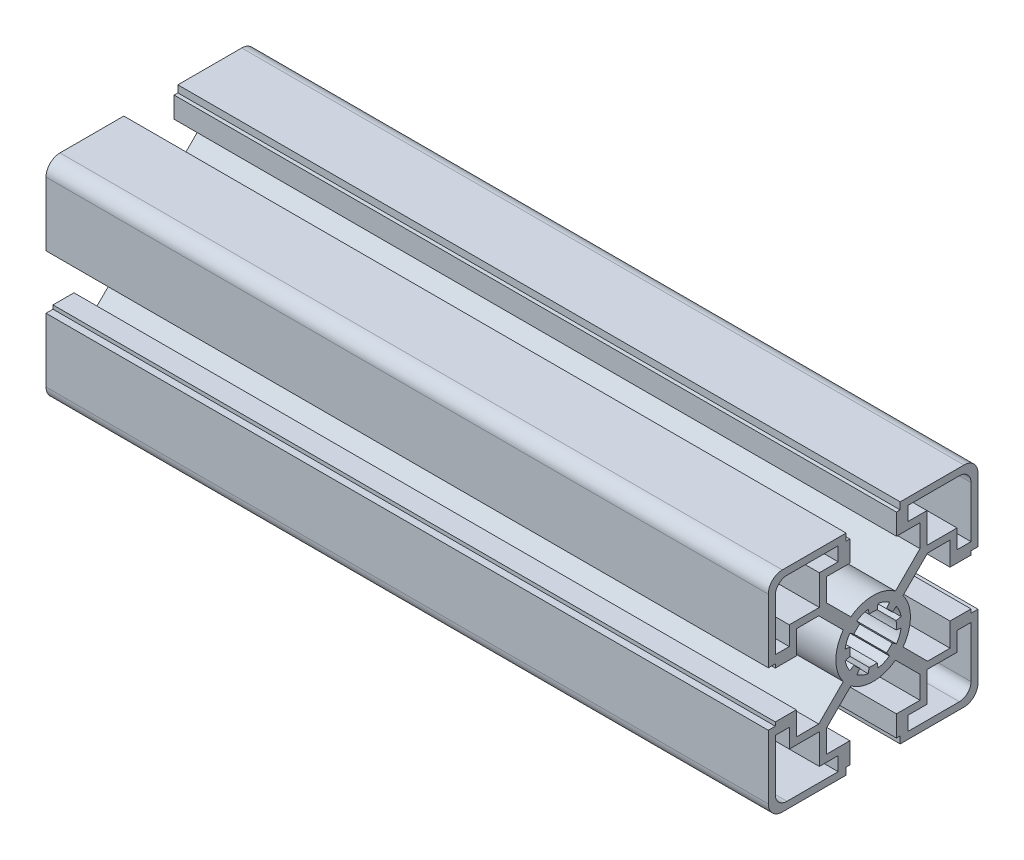
from build123d import *

# Parameters (mm, degrees)
BR_EXTRUDE_DEPTH      = 77.5
BR_EXTRUDE_DEPTH_BACK = 77.5


with BuildPart() as part:
    # Sketch2 → BR_Extrude (new body, two sides)
    with BuildSketch(Plane(origin=(0, 0, 0), x_dir=(0, 0, -1), z_dir=(1, 0, 0))) as br_extrude_sk:
        with BuildLine():
            Line((-10.05, 11.676345597), (-10.05, 16.5))
            Line((-10.05, 16.5), (-5, 16.5))
            Line((-5, 16.5), (-5, 21))
            Line((-5, 21), (-5.8, 21))
            Line((-5.8, 21), (-5.8, 22.5))
            Line((-5.8, 22.5), (-19.5, 22.5))
            ThreePointArc((-19.5, 22.5), (-21.621320344, 21.621320344), (-22.5, 19.5))
            Line((-22.5, 19.5), (-22.5, 5.8))
            Line((-22.5, 5.8), (-21, 5.8))
            Line((-21, 5.8), (-21, 5))
            Line((-21, 5), (-16.5, 5))
            Line((-16.5, 5), (-16.5, 10.05))
            Line((-16.5, 10.05), (-11.676345597, 10.05))
            Line((-11.676345597, 10.05), (-6.411275155, 4.784929559))
            ThreePointArc((-6.411275155, 4.784929559), (-8, 0), (-6.411275155, -4.784929559))
            Line((-6.411275155, -4.784929559), (-11.676345597, -10.05))
            Line((-11.676345597, -10.05), (-16.5, -10.05))
            Line((-16.5, -10.05), (-16.5, -5))
            Line((-16.5, -5), (-21, -5))
            Line((-21, -5), (-21, -5.8))
            Line((-21, -5.8), (-22.5, -5.8))
            Line((-22.5, -5.8), (-22.5, -19.5))
            ThreePointArc((-22.5, -19.5), (-21.621320344, -21.621320344), (-19.5, -22.5))
            Line((-19.5, -22.5), (-5.8, -22.5))
            Line((-5.8, -22.5), (-5.8, -21))
            Line((-5.8, -21), (-5, -21))
            Line((-5, -21), (-5, -16.5))
            Line((-5, -16.5), (-10.05, -16.5))
            Line((-10.05, -16.5), (-10.05, -11.676345597))
            Line((-10.05, -11.676345597), (-4.784929559, -6.411275155))
            ThreePointArc((-4.784929559, -6.411275155), (0, -8), (4.784929559, -6.411275155))
            Line((4.784929559, -6.411275155), (10.05, -11.676345597))
            Line((10.05, -11.676345597), (10.05, -16.5))
            Line((10.05, -16.5), (5, -16.5))
            Line((5, -16.5), (5, -21))
            Line((5, -21), (5.8, -21))
            Line((5.8, -21), (5.8, -22.5))
            Line((5.8, -22.5), (19.5, -22.5))
            ThreePointArc((19.5, -22.5), (21.621320344, -21.621320344), (22.5, -19.5))
            Line((22.5, -19.5), (22.5, -5.8))
            Line((22.5, -5.8), (21, -5.8))
            Line((21, -5.8), (21, -5))
            Line((21, -5), (16.5, -5))
            Line((16.5, -5), (16.5, -10.05))
            Line((16.5, -10.05), (11.676345597, -10.05))
            Line((11.676345597, -10.05), (6.411275155, -4.784929559))
            ThreePointArc((6.411275155, -4.784929559), (8, 0), (6.411275155, 4.784929559))
            Line((6.411275155, 4.784929559), (11.676345597, 10.05))
            Line((11.676345597, 10.05), (16.5, 10.05))
            Line((16.5, 10.05), (16.5, 5))
            Line((16.5, 5), (21, 5))
            Line((21, 5), (21, 5.8))
            Line((21, 5.8), (22.5, 5.8))
            Line((22.5, 5.8), (22.5, 19.5))
            ThreePointArc((22.5, 19.5), (21.621320344, 21.621320344), (19.5, 22.5))
            Line((19.5, 22.5), (5.8, 22.5))
            Line((5.8, 22.5), (5.8, 21))
            Line((5.8, 21), (5, 21))
            Line((5, 21), (5, 16.5))
            Line((5, 16.5), (10.05, 16.5))
            Line((10.05, 16.5), (10.05, 11.676345597))
            Line((10.05, 11.676345597), (4.784929559, 6.411275155))
            ThreePointArc((4.784929559, 6.411275155), (0, 8), (-4.784929559, 6.411275155))
            Line((-4.784929559, 6.411275155), (-10.05, 11.676345597))
        make_face()
        with BuildLine():
            Line((11.55, 11.55), (11.55, 18))
            Line((11.55, 18), (7.5, 18))
            Line((7.5, 18), (7.5, 21))
            Line((7.5, 21), (18.5, 21))
            ThreePointArc((18.5, 21), (20.267766953, 20.267766953), (21, 18.5))
            Line((21, 18.5), (21, 7.5))
            Line((21, 7.5), (18, 7.5))
            Line((18, 7.5), (18, 11.55))
            Line((18, 11.55), (11.55, 11.55))
        make_face(mode=Mode.SUBTRACT)
        with BuildLine():
            Line((11.55, -11.55), (18, -11.55))
            Line((18, -11.55), (18, -7.5))
            Line((18, -7.5), (21, -7.5))
            Line((21, -7.5), (21, -18.5))
            ThreePointArc((21, -18.5), (20.267766953, -20.267766953), (18.5, -21))
            Line((18.5, -21), (7.5, -21))
            Line((7.5, -21), (7.5, -18))
            Line((7.5, -18), (11.55, -18))
            Line((11.55, -18), (11.55, -11.55))
        make_face(mode=Mode.SUBTRACT)
        with BuildLine():
            Line((-11.55, 11.55), (-18, 11.55))
            Line((-18, 11.55), (-18, 7.5))
            Line((-18, 7.5), (-21, 7.5))
            Line((-21, 7.5), (-21, 18.5))
            ThreePointArc((-21, 18.5), (-20.267766953, 20.267766953), (-18.5, 21))
            Line((-18.5, 21), (-7.5, 21))
            Line((-7.5, 21), (-7.5, 18))
            Line((-7.5, 18), (-11.55, 18))
            Line((-11.55, 18), (-11.55, 11.55))
        make_face(mode=Mode.SUBTRACT)
        with BuildLine():
            Line((-11.55, -11.55), (-11.55, -18))
            Line((-11.55, -18), (-7.5, -18))
            Line((-7.5, -18), (-7.5, -21))
            Line((-7.5, -21), (-18.5, -21))
            ThreePointArc((-18.5, -21), (-20.267766953, -20.267766953), (-21, -18.5))
            Line((-21, -18.5), (-21, -7.5))
            Line((-21, -7.5), (-18, -7.5))
            Line((-18, -7.5), (-18, -11.55))
            Line((-18, -11.55), (-11.55, -11.55))
        make_face(mode=Mode.SUBTRACT)
        with BuildLine():
            Line((-6.007327293, -1.059253884), (-4.924038765, -0.868240888))
            ThreePointArc((-4.924038765, -0.868240888), (-5, 0), (-4.924038765, 0.868240888))
            Line((-4.924038765, 0.868240888), (-6.007327293, 1.059253884))
            ThreePointArc((-6.007327293, 1.059253884), (-5.635665148, 2.334368937), (-4.99682747, 3.498816262))
            Line((-4.99682747, 3.498816262), (-4.095760221, 2.867882182))
            ThreePointArc((-4.095760221, 2.867882182), (-3.535533906, 3.535533906), (-2.867882182, 4.095760221))
            Line((-2.867882182, 4.095760221), (-3.498816262, 4.99682747))
            ThreePointArc((-3.498816262, 4.99682747), (-2.334368937, 5.635665148), (-1.059253884, 6.007327293))
            Line((-1.059253884, 6.007327293), (-0.868240888, 4.924038765))
            ThreePointArc((-0.868240888, 4.924038765), (0, 5), (0.868240888, 4.924038765))
            Line((0.868240888, 4.924038765), (1.059253884, 6.007327293))
            ThreePointArc((1.059253884, 6.007327293), (2.334368937, 5.635665148), (3.498816262, 4.99682747))
            Line((3.498816262, 4.99682747), (2.867882182, 4.095760221))
            ThreePointArc((2.867882182, 4.095760221), (3.535533906, 3.535533906), (4.095760221, 2.867882182))
            Line((4.095760221, 2.867882182), (4.99682747, 3.498816262))
            ThreePointArc((4.99682747, 3.498816262), (5.635665148, 2.334368937), (6.007327293, 1.059253884))
            Line((6.007327293, 1.059253884), (4.924038765, 0.868240888))
            ThreePointArc((4.924038765, 0.868240888), (5, 0), (4.924038765, -0.868240888))
            Line((4.924038765, -0.868240888), (6.007327293, -1.059253884))
            ThreePointArc((6.007327293, -1.059253884), (5.635665148, -2.334368937), (4.99682747, -3.498816262))
            Line((4.99682747, -3.498816262), (4.095760221, -2.867882182))
            ThreePointArc((4.095760221, -2.867882182), (3.535533906, -3.535533906), (2.867882182, -4.095760221))
            Line((2.867882182, -4.095760221), (3.498816262, -4.99682747))
            ThreePointArc((3.498816262, -4.99682747), (2.334368937, -5.635665148), (1.059253884, -6.007327293))
            Line((1.059253884, -6.007327293), (0.868240888, -4.924038765))
            ThreePointArc((0.868240888, -4.924038765), (0, -5), (-0.868240888, -4.924038765))
            Line((-0.868240888, -4.924038765), (-1.059253884, -6.007327293))
            ThreePointArc((-1.059253884, -6.007327293), (-2.334368937, -5.635665148), (-3.498816262, -4.99682747))
            Line((-3.498816262, -4.99682747), (-2.867882182, -4.095760221))
            ThreePointArc((-2.867882182, -4.095760221), (-3.535533906, -3.535533906), (-4.095760221, -2.867882182))
            Line((-4.095760221, -2.867882182), (-4.99682747, -3.498816262))
            ThreePointArc((-4.99682747, -3.498816262), (-5.635665148, -2.334368937), (-6.007327293, -1.059253884))
        make_face(mode=Mode.SUBTRACT)
    extrude(amount=BR_EXTRUDE_DEPTH)
    extrude(br_extrude_sk.sketch, amount=-BR_EXTRUDE_DEPTH_BACK)


solid = part.part
